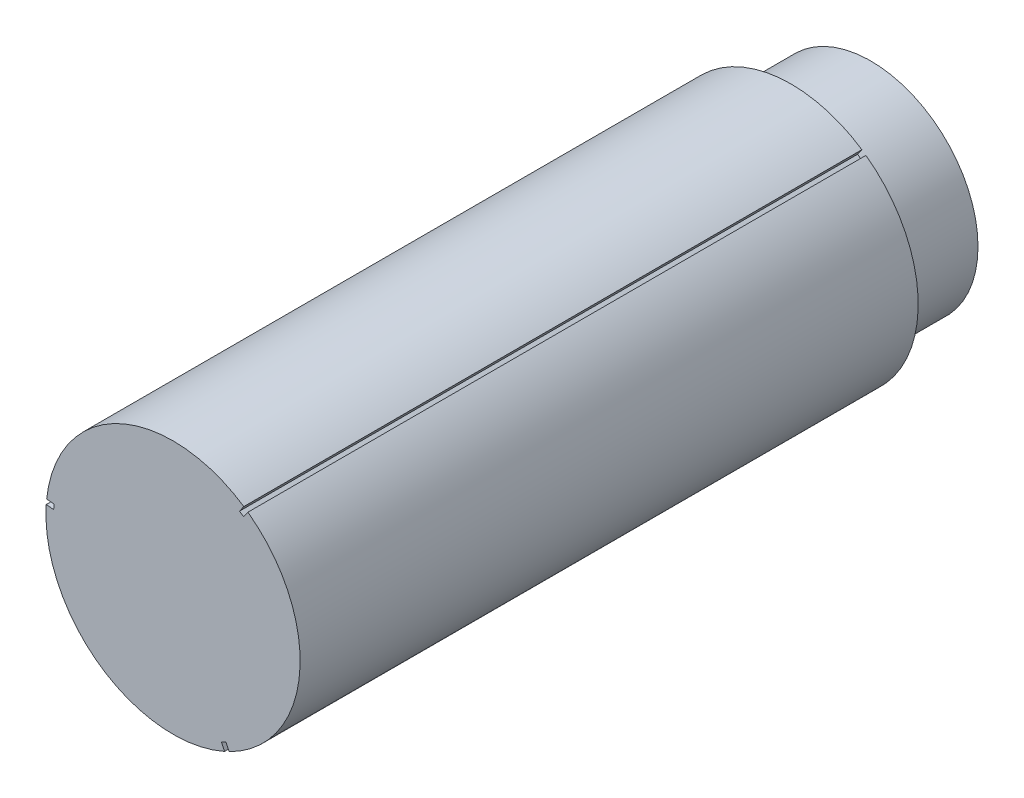
from build123d import *

# Parameters (mm, degrees)
ESQUISSE1_R             = 10.75
ESQUISSE1_R_2           = 2.75
BASE_EXTRUSION_DEPTH    = 8
ESQUISSE2_R             = 12.75
BOSS_EXTRU_1_DEPTH      = 62
ENL_V_MAT_EXTRU_1_REACH = 72


with BuildPart() as part:
    # Esquisse1 → Base-Extrusion (new body)
    with BuildSketch(Plane.XY):
        Circle(ESQUISSE1_R)
        Circle(ESQUISSE1_R_2, mode=Mode.SUBTRACT)
    extrude(amount=BASE_EXTRUSION_DEPTH)

    # Esquisse2 → Boss.-Extru.1 (add)
    with BuildSketch(Plane.XY.offset(8)):
        Circle(ESQUISSE2_R)
    extrude(amount=BOSS_EXTRU_1_DEPTH)

    # Esquisse4 → Enlèv. mat.-Extru.1 (cut, up to next)
    with BuildSketch(Plane.XY.offset(70), mode=Mode.PRIVATE) as enl_v_mat_extru_1_sk1:
        with BuildLine():
            Line((7.10084197, 10.58964321), (6.672416375, 9.977041632))
            Line((6.672416375, 9.977041632), (7.082156576, 9.690488028))
            Line((7.082156576, 9.690488028), (7.510582172, 10.303089607))
            ThreePointArc((7.510582172, 10.303089607), (7.30711688, 10.448375132), (7.10084197, 10.58964321))
        make_face()
    enl_v_mat_extru_1_tool1 = extrude(enl_v_mat_extru_1_sk1.sketch, amount=-ENL_V_MAT_EXTRU_1_REACH, mode=Mode.PRIVATE) & part.part
    add(enl_v_mat_extru_1_tool1.solids().sort_by_distance((7.091968, 10.140735, 70))[0], mode=Mode.SUBTRACT)
    # Esquisse4 → Enlèv. mat.-Extru.1 (cut, up to next)
    with BuildSketch(Plane.XY.offset(70), mode=Mode.PRIVATE) as enl_v_mat_extru_1_sk2:
        with BuildLine():
            Line((5.620479052, -11.444331139), (5.30416332, -10.767002901))
            Line((5.30416332, -10.767002901), (4.851130519, -10.978571523))
            Line((4.851130519, -10.978571523), (5.167446251, -11.655899761))
            ThreePointArc((5.167446251, -11.655899761), (5.394999852, -11.552336413), (5.620479052, -11.444331139))
        make_face()
    enl_v_mat_extru_1_tool2 = extrude(enl_v_mat_extru_1_sk2.sketch, amount=-ENL_V_MAT_EXTRU_1_REACH, mode=Mode.PRIVATE) & part.part
    add(enl_v_mat_extru_1_tool2.solids().sort_by_distance((5.236151, -11.212192, 70))[0], mode=Mode.SUBTRACT)
    # Esquisse4 → Enlèv. mat.-Extru.1 (cut, up to next)
    with BuildSketch(Plane.XY.offset(70), mode=Mode.PRIVATE) as enl_v_mat_extru_1_sk3:
        with BuildLine():
            Line((-12.721321022, 0.85468793), (-11.976579695, 0.78996127))
            Line((-11.976579695, 0.78996127), (-11.933287096, 1.288083495))
            Line((-11.933287096, 1.288083495), (-12.678028423, 1.352810154))
            ThreePointArc((-12.678028423, 1.352810154), (-12.702116733, 1.103961281), (-12.721321022, 0.85468793))
        make_face()
    enl_v_mat_extru_1_tool3 = extrude(enl_v_mat_extru_1_sk3.sketch, amount=-ENL_V_MAT_EXTRU_1_REACH, mode=Mode.PRIVATE) & part.part
    add(enl_v_mat_extru_1_tool3.solids().sort_by_distance((-12.328118, 1.071456, 70))[0], mode=Mode.SUBTRACT)


solid = part.part
